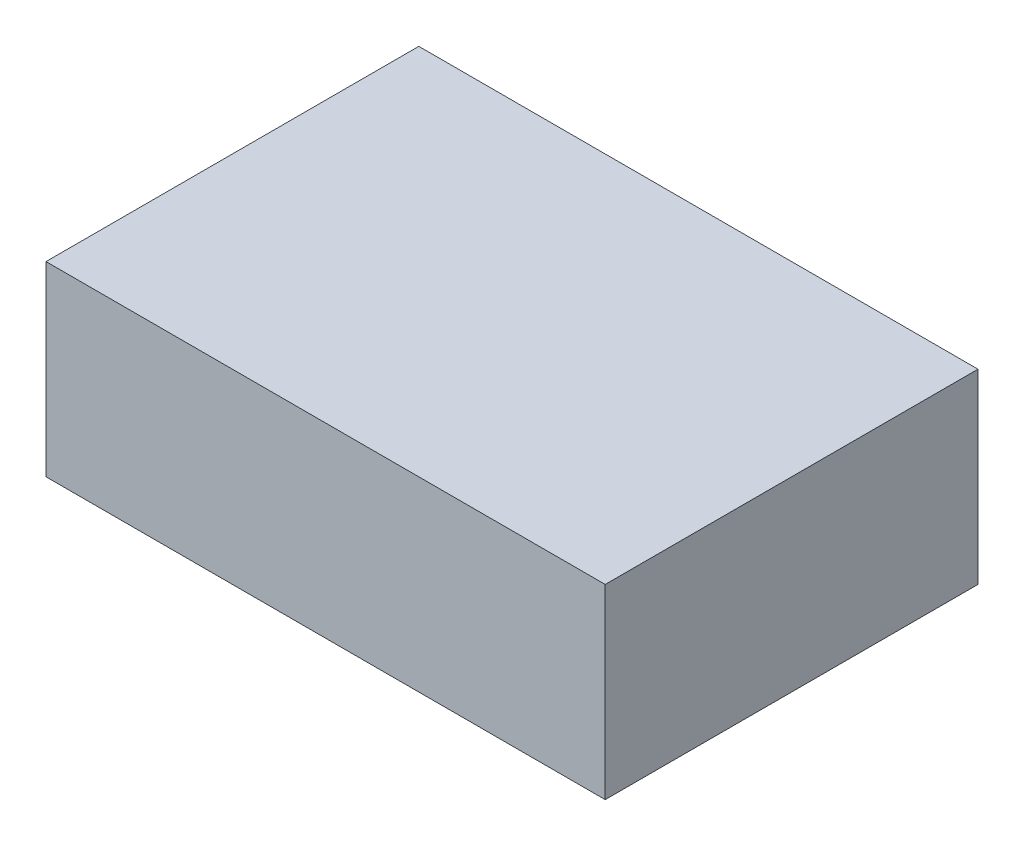
from build123d import *

# Parameters (mm, degrees)
SKETCH1_W           = 150
SKETCH1_H           = 100
BOSS_EXTRUDE1_DEPTH = 50


with BuildPart() as part:
    # Sketch1 → Boss-Extrude1 (new body)
    with BuildSketch(Plane(origin=(0, 0, 0), x_dir=(1, 0, 0), z_dir=(0, 1, 0))):
        Rectangle(SKETCH1_W, SKETCH1_H)
    extrude(amount=BOSS_EXTRUDE1_DEPTH)


solid = part.part
